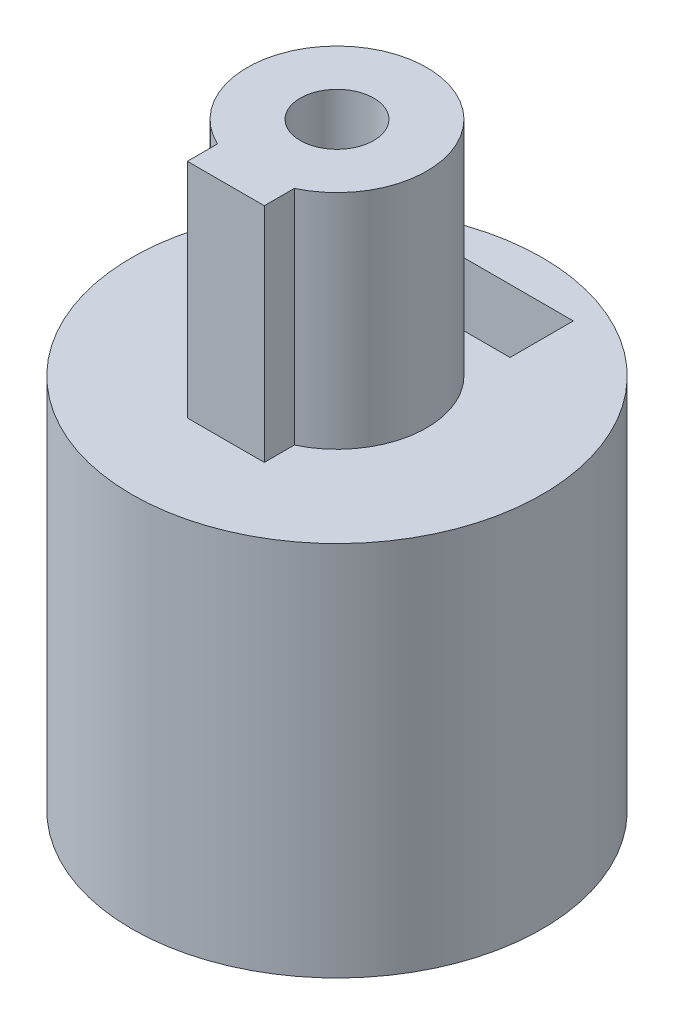
from build123d import *

# Parameters (mm, degrees)
SKETCH1_R           = 6
BOSS_EXTRUDE1_DEPTH = 10
SKETCH2_R           = 1.025
CUT_EXTRUDE1_DEPTH  = 7
SKETCH4_R           = 2.1
CUT_EXTRUDE4_DEPTH  = 11.0000001
SKETCH5_W           = 0.95
SKETCH5_H           = 7.069146706
BOSS_EXTRUDE2_DEPTH = 1.2
SKETCH7_R           = 6
BOSS_EXTRUDE3_DEPTH = 1
SKETCH8_R           = 2.625
SKETCH8_W           = 2.25
SKETCH8_H           = 1.25
BOSS_EXTRUDE4_DEPTH = 6.5
SKETCH9_R           = 1.075
CUT_EXTRUDE5_DEPTH  = 6
CUT_EXTRUDE2_START  = -3
CUT_EXTRUDE2_DEPTH  = 1.85


with BuildPart() as part:
    # Sketch1 → Boss-Extrude1 (new body)
    with BuildSketch(Plane(origin=(0, 0, 0), x_dir=(1, 0, 0), z_dir=(0, 1, 0))):
        Circle(SKETCH1_R)
    extrude(amount=BOSS_EXTRUDE1_DEPTH)

    # Sketch2 → Cut-Extrude1 (cut, through all)
    with BuildSketch(Plane.XY):
        with Locations((0, 7)):
            Circle(SKETCH2_R)
    extrude(amount=-CUT_EXTRUDE1_DEPTH, mode=Mode.SUBTRACT)

    # Sketch4 → Cut-Extrude4 (cut, through all)
    with BuildSketch(Plane(origin=(0, 0, 0), x_dir=(1, 0, 0), z_dir=(0, 1, 0))):
        Circle(SKETCH4_R)
    extrude(amount=CUT_EXTRUDE4_DEPTH, mode=Mode.SUBTRACT)

    # Sketch5 → Boss-Extrude2 (add)
    with BuildSketch(Plane(origin=(0, 10, 0), x_dir=(1, 0, 0), z_dir=(0, 1, 0))):
        Rectangle(SKETCH5_W, SKETCH5_H)
    extrude(amount=-BOSS_EXTRUDE2_DEPTH)

    # Sketch7 → Boss-Extrude3 (add)
    with BuildSketch(Plane(origin=(0, 10, 0), x_dir=(1, 0, 0), z_dir=(0, 1, 0))):
        Circle(SKETCH7_R)
    extrude(amount=BOSS_EXTRUDE3_DEPTH)

    # Sketch8 → Boss-Extrude4 (add)
    with BuildSketch(Plane(origin=(0, 11, 0), x_dir=(1, 0, 0), z_dir=(0, 1, 0))):
        Circle(SKETCH8_R)
        with Locations((0, -2.625)):
            Rectangle(SKETCH8_W, SKETCH8_H)
    extrude(amount=BOSS_EXTRUDE4_DEPTH)

    # Sketch9 → Cut-Extrude5 (cut)
    with BuildSketch(Plane(origin=(0, 17.5, 0), x_dir=(1, 0, 0), z_dir=(0, 1, 0))):
        Circle(SKETCH9_R)
    extrude(amount=-CUT_EXTRUDE5_DEPTH, mode=Mode.SUBTRACT)

    # Sketch3 → Cut-Extrude2 (cut)
    with BuildSketch(Plane.XY.offset(CUT_EXTRUDE2_START)):
        Polygon((0, 4.621316891), (2.06, 5.810658445), (2.06, 8.189341555), (2.06, 11.363105915), (-2.06, 11.363105915), (-2.06, 8.189341555), (-2.06, 5.810658445), align=None)
    extrude(amount=-CUT_EXTRUDE2_DEPTH, mode=Mode.SUBTRACT)


solid = part.part
